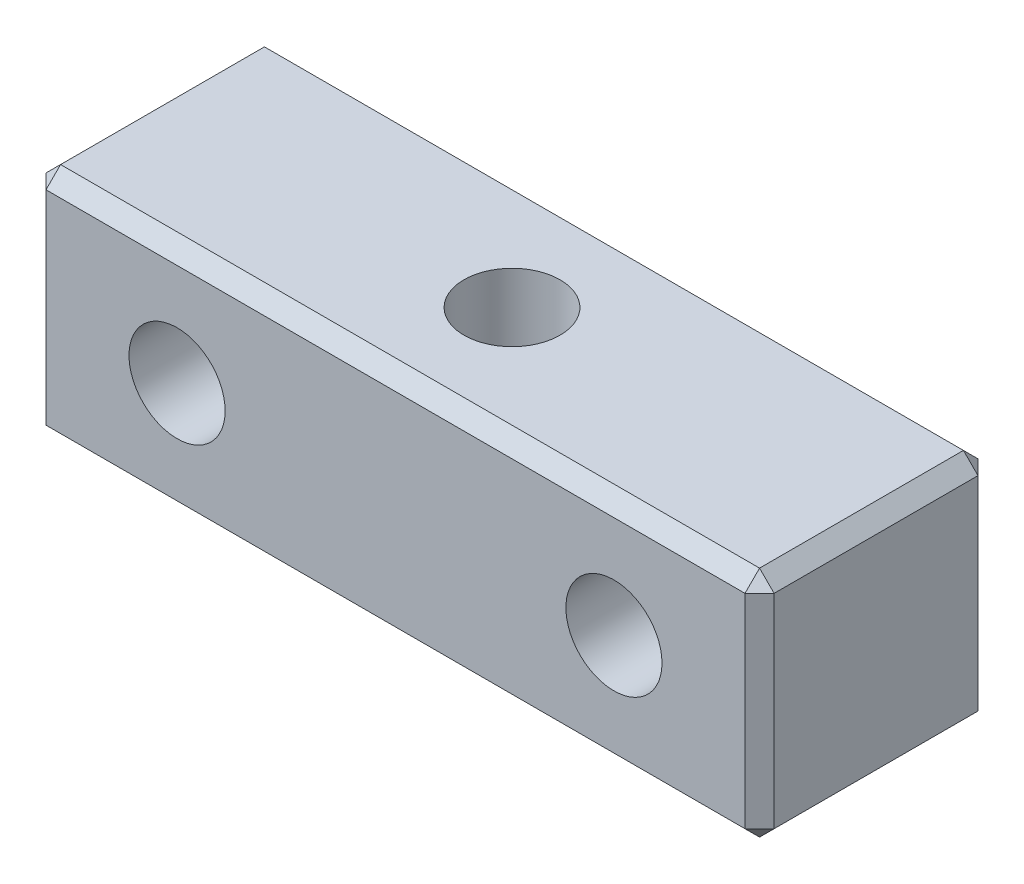
from build123d import *

# Parameters (mm, degrees)
SKETCH_1_W         = 25
SKETCH_1_H         = 8
EXTRUDE_1_DEPTH    = 8
CHAMFER_1_SIZE     = 0.5
HOLE_WIZARD_M4_1_D = 3.3
HOLE_WIZARD_M4_2_D = 3.3


with BuildPart() as part:
    # 草图1 → 凸台-拉伸1 (new body)
    with BuildSketch(Plane.XY):
        Rectangle(SKETCH_1_W, SKETCH_1_H)
    extrude(amount=EXTRUDE_1_DEPTH)

    # 倒角1
    chamfer_1_edges = [part.edges().sort_by_distance(p)[0] for p in [
        (-12.5, 0, 8),
        (0, -4, 8),
        (12.5, 0, 8),
        (0, -4, 0),
        (-12.5, 0, 0),
        (0, 4, 0),
        (12.5, 0, 0),
        (12.5, -4, 4),
        (-12.5, -4, 4),
        (-12.5, 4, 4),
        (12.5, 4, 4),
        (0, 4, 8),
    ]]
    chamfer(chamfer_1_edges, length=CHAMFER_1_SIZE)

    # M4 螺纹孔1 (through all)
    with Locations(Plane(origin=(0, -4, 4), x_dir=(0, 0, -1), z_dir=(0, -1, 0))):
        with Locations((0, 0)):
            Hole(HOLE_WIZARD_M4_1_D / 2)

    # M4 螺纹孔2 (through all)
    with Locations(Plane(origin=(-7.5, 0, 8), x_dir=(1, 0, 0), z_dir=(0, 0, 1))):
        with Locations((0, 0), (15, 0)):
            Hole(HOLE_WIZARD_M4_2_D / 2)


solid = part.part
